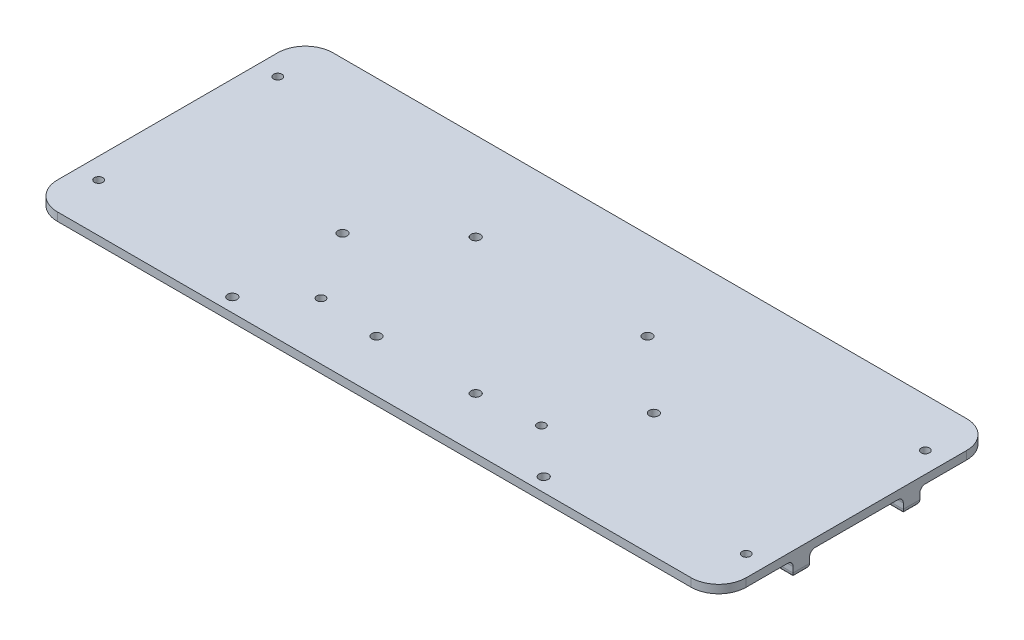
from build123d import *

# Parameters (mm, degrees)
SKETCH_1_W          = 250
SKETCH_1_H          = 100
EXTRUDE_1_DEPTH     = 3
FILLET_1_R          = 10
SKETCH_2_R          = 1.525
CUT_EXTRUDE_1_DEPTH = 3
SKETCH_3_R          = 1.525
CUT_EXTRUDE_2_DEPTH = 3
SKETCH_4_W          = 250
SKETCH_4_H          = 6
EXTRUDE_2_DEPTH     = 6
FILLET_2_R          = 2
CUT_EXTRUDE_3_REACH = 11
SKETCH_5_R          = 1.7
CUT_EXTRUDE_4_REACH = 11
SKETCH_6_R          = 1.7
SKETCH_7_W          = 13
SKETCH_7_H          = 10
CUT_EXTRUDE_5_DEPTH = 3
FILLET_3_R          = 2


with BuildPart() as part:
    # 草图1 → 凸台-拉伸1 (new body)
    with BuildSketch(Plane(origin=(0, 0, 0), x_dir=(1, 0, 0), z_dir=(0, 1, 0))):
        Rectangle(SKETCH_1_W, SKETCH_1_H)
    extrude(amount=EXTRUDE_1_DEPTH)

    # 圆角1
    fillet_1_edges = [part.edges().sort_by_distance(p)[0] for p in [
        (125, 1.5, 50),
        (-125, 1.5, 50),
        (-125, 1.5, -50),
        (125, 1.5, -50),
    ]]
    fillet(fillet_1_edges, radius=FILLET_1_R)

    # 草图2 → 切除-拉伸1 (cut)
    with BuildSketch(Plane(origin=(0, 3, 0), x_dir=(1, 0, 0), z_dir=(0, 1, 0))):
        with Locations((-117.5, 32.5)):
            Circle(SKETCH_2_R)
        with Locations((117.5, 32.5)):
            Circle(SKETCH_2_R)
        with Locations((117.5, -32.5)):
            Circle(SKETCH_2_R)
        with Locations((-117.5, -32.5)):
            Circle(SKETCH_2_R)
    extrude(amount=-CUT_EXTRUDE_1_DEPTH, mode=Mode.SUBTRACT)

    # 草图3 → 切除-拉伸2 (cut)
    with BuildSketch(Plane(origin=(0, 3, 0), x_dir=(1, 0, 0), z_dir=(0, 1, 0))):
        with Locations((-40, -29.33)):
            Circle(SKETCH_3_R)
        with Locations((40, -29.33)):
            Circle(SKETCH_3_R)
    extrude(amount=-CUT_EXTRUDE_2_DEPTH, mode=Mode.SUBTRACT)

    # 草图4 → 凸台-拉伸2 (add)
    with BuildSketch(Plane.XZ):
        with Locations((0, 20)):
            Rectangle(SKETCH_4_W, SKETCH_4_H)
        with Locations((0, -20)):
            Rectangle(SKETCH_4_W, SKETCH_4_H)
    extrude(amount=EXTRUDE_2_DEPTH)

    # 圆角2
    fillet_2_edges = [part.edges().sort_by_distance(p)[0] for p in [
        (0, 0, 17),
        (0, 0, 23),
        (-125, -6, 20),
        (0, -6, 17),
        (125, -6, 20),
        (0, -6, 23),
        (0, 0, -23),
        (0, 0, -17),
        (-125, -6, -20),
        (0, -6, -23),
        (125, -6, -20),
        (0, -6, -17),
    ]]
    fillet(fillet_2_edges, radius=FILLET_2_R)

    # 草图5 → 切除-拉伸3 (cut, up to next)
    with BuildSketch(Plane(origin=(0, 3, 0), x_dir=(1, 0, 0), z_dir=(0, 1, 0)), mode=Mode.PRIVATE) as cut_extrude_3_sk1:
        with Locations((-31.176914536, 18)):
            Circle(SKETCH_5_R)
    cut_extrude_3_tool1 = extrude(cut_extrude_3_sk1.sketch, amount=-CUT_EXTRUDE_3_REACH, mode=Mode.PRIVATE) & part.part
    add(cut_extrude_3_tool1.solids().sort_by_distance((-31.176915, 3, -18))[0], mode=Mode.SUBTRACT)
    # 草图5 → 切除-拉伸3 (cut, up to next)
    with BuildSketch(Plane(origin=(0, 3, 0), x_dir=(1, 0, 0), z_dir=(0, 1, 0)), mode=Mode.PRIVATE) as cut_extrude_3_sk2:
        with Locations((31.176914536, 18)):
            Circle(SKETCH_5_R)
    cut_extrude_3_tool2 = extrude(cut_extrude_3_sk2.sketch, amount=-CUT_EXTRUDE_3_REACH, mode=Mode.PRIVATE) & part.part
    add(cut_extrude_3_tool2.solids().sort_by_distance((31.176915, 3, -18))[0], mode=Mode.SUBTRACT)
    # 草图5 → 切除-拉伸3 (cut, up to next)
    with BuildSketch(Plane(origin=(0, 3, 0), x_dir=(1, 0, 0), z_dir=(0, 1, 0)), mode=Mode.PRIVATE) as cut_extrude_3_sk3:
        with Locations((-18, -31.176914536)):
            Circle(SKETCH_5_R)
    cut_extrude_3_tool3 = extrude(cut_extrude_3_sk3.sketch, amount=-CUT_EXTRUDE_3_REACH, mode=Mode.PRIVATE) & part.part
    add(cut_extrude_3_tool3.solids().sort_by_distance((-18, 3, 31.176915))[0], mode=Mode.SUBTRACT)
    # 草图5 → 切除-拉伸3 (cut, up to next)
    with BuildSketch(Plane(origin=(0, 3, 0), x_dir=(1, 0, 0), z_dir=(0, 1, 0)), mode=Mode.PRIVATE) as cut_extrude_3_sk4:
        with Locations((18, -31.176914536)):
            Circle(SKETCH_5_R)
    cut_extrude_3_tool4 = extrude(cut_extrude_3_sk4.sketch, amount=-CUT_EXTRUDE_3_REACH, mode=Mode.PRIVATE) & part.part
    add(cut_extrude_3_tool4.solids().sort_by_distance((18, 3, 31.176915))[0], mode=Mode.SUBTRACT)

    # 草图6 → 切除-拉伸4 (cut, up to next)
    with BuildSketch(Plane(origin=(0, 3, 0), x_dir=(1, 0, 0), z_dir=(0, 1, 0)), mode=Mode.PRIVATE) as cut_extrude_4_sk1:
        with Locations((-56.5, -5)):
            Circle(SKETCH_6_R)
    cut_extrude_4_tool1 = extrude(cut_extrude_4_sk1.sketch, amount=-CUT_EXTRUDE_4_REACH, mode=Mode.PRIVATE) & part.part
    add(cut_extrude_4_tool1.solids().sort_by_distance((-56.5, 3, 5))[0], mode=Mode.SUBTRACT)
    # 草图6 → 切除-拉伸4 (cut, up to next)
    with BuildSketch(Plane(origin=(0, 3, 0), x_dir=(1, 0, 0), z_dir=(0, 1, 0)), mode=Mode.PRIVATE) as cut_extrude_4_sk2:
        with Locations((56.5, -5)):
            Circle(SKETCH_6_R)
    cut_extrude_4_tool2 = extrude(cut_extrude_4_sk2.sketch, amount=-CUT_EXTRUDE_4_REACH, mode=Mode.PRIVATE) & part.part
    add(cut_extrude_4_tool2.solids().sort_by_distance((56.5, 3, 5))[0], mode=Mode.SUBTRACT)
    # 草图6 → 切除-拉伸4 (cut, up to next)
    with BuildSketch(Plane(origin=(0, 3, 0), x_dir=(1, 0, 0), z_dir=(0, 1, 0)), mode=Mode.PRIVATE) as cut_extrude_4_sk3:
        with Locations((-56.5, -45)):
            Circle(SKETCH_6_R)
    cut_extrude_4_tool3 = extrude(cut_extrude_4_sk3.sketch, amount=-CUT_EXTRUDE_4_REACH, mode=Mode.PRIVATE) & part.part
    add(cut_extrude_4_tool3.solids().sort_by_distance((-56.5, 3, 45))[0], mode=Mode.SUBTRACT)
    # 草图6 → 切除-拉伸4 (cut, up to next)
    with BuildSketch(Plane(origin=(0, 3, 0), x_dir=(1, 0, 0), z_dir=(0, 1, 0)), mode=Mode.PRIVATE) as cut_extrude_4_sk4:
        with Locations((56.5, -45)):
            Circle(SKETCH_6_R)
    cut_extrude_4_tool4 = extrude(cut_extrude_4_sk4.sketch, amount=-CUT_EXTRUDE_4_REACH, mode=Mode.PRIVATE) & part.part
    add(cut_extrude_4_tool4.solids().sort_by_distance((56.5, 3, 45))[0], mode=Mode.SUBTRACT)

    # 草图7 → 切除-拉伸5 (cut)
    with BuildSketch(Plane.XZ.offset(6)):
        with Locations((-56.5, 20)):
            Rectangle(SKETCH_7_W, SKETCH_7_H)
        with Locations((56.5, 20)):
            Rectangle(SKETCH_7_W, SKETCH_7_H)
    extrude(amount=-CUT_EXTRUDE_5_DEPTH, mode=Mode.SUBTRACT)

    # 圆角3
    fillet_3_edges = [part.edges().sort_by_distance(p)[0] for p in [
        (-63, -5.414213562, 22.414213562),
        (-50, -5.414213562, 22.414213562),
        (50, -5.414213562, 22.414213562),
        (63, -5.414213562, 22.414213562),
        (63, -3.5, 17),
        (63, -3.5, 23),
        (63, -5.414213562, 17.585786438),
        (50, -3.5, 17),
        (50, -3.5, 23),
        (50, -5.414213562, 17.585786438),
        (63, -6, 20),
        (50, -6, 20),
        (-50, -3.5, 17),
        (-50, -3.5, 23),
        (-50, -5.414213562, 17.585786438),
        (-63, -3.5, 17),
        (-63, -3.5, 23),
        (-63, -5.414213562, 17.585786438),
        (-50, -6, 20),
        (-63, -6, 20),
    ]]
    fillet(fillet_3_edges, radius=FILLET_3_R)


solid = part.part
